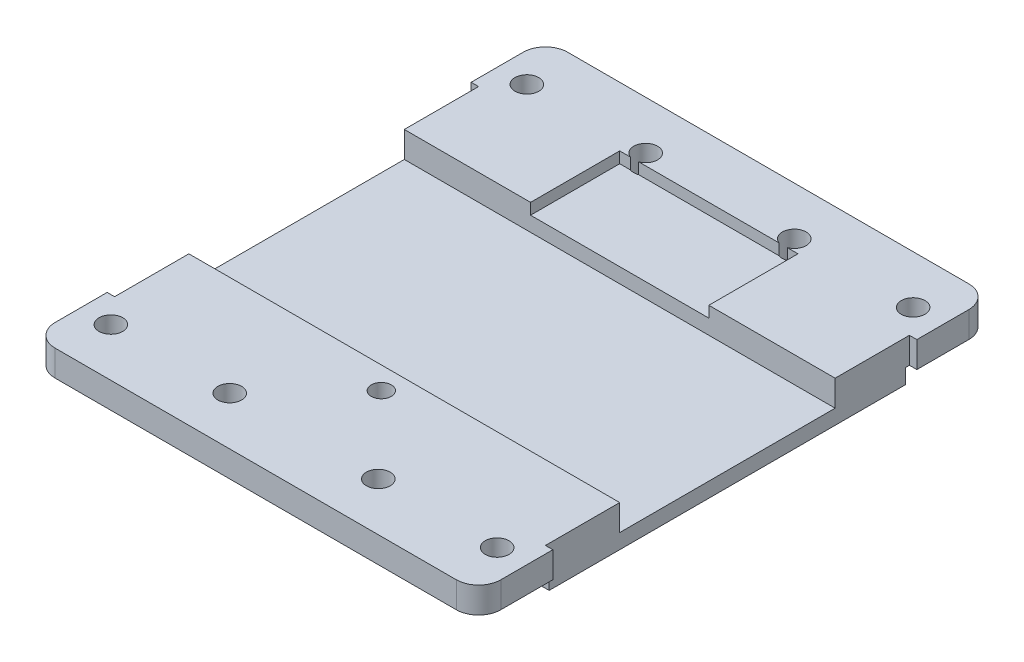
from build123d import *

# Parameters (mm, degrees)
SKETCH1_W           = 60
SKETCH1_H           = 48
BOSS_EXTRUDE1_DEPTH = 2
BOSS_EXTRUDE2_DEPTH = 3.5
SKETCH3_W           = 6.52386431
SKETCH3_H           = 49
SKETCH3_W_2         = 6.523864309
CUT_EXTRUDE2_DEPTH  = 15
SKETCH4_W           = 24
SKETCH4_H           = 12
CUT_EXTRUDE3_DEPTH  = 1.5
SKETCH5_R           = 1.35
CUT_EXTRUDE4_DEPTH  = 3
SKETCH6_R           = 1.35
CUT_EXTRUDE5_DEPTH  = 3
SKETCH7_W           = 69.929961246
SKETCH7_H           = 12.314710156
SKETCH7_W_2         = 77.406749556
SKETCH7_H_2         = 16.199708004
CUT_EXTRUDE6_DEPTH  = 2
SKETCH8_R           = 1.6
CUT_EXTRUDE7_DEPTH  = 18
SKETCH9_W           = 6.597166155
SKETCH9_H           = 6.303958771
SKETCH9_W_2         = 5.93744954
SKETCH9_H_2         = 5.497638462
SKETCH9_W_3         = 7.769995694
SKETCH9_W_4         = 5.131129232
SKETCH9_H_3         = 5.204431078
SKETCH9_W_5         = 5.497638463
SKETCH9_H_4         = 5.0930957
SKETCH9_W_6         = 4.691318155
BOSS_EXTRUDE3_DEPTH = 3.5
SKETCH10_W          = 13.673673514
SKETCH10_H          = 2.686711401
SKETCH10_W_2        = 10.911645047
SKETCH10_H_2        = 3.141048784
SKETCH10_W_3        = 10.921694408
SKETCH10_H_3        = 3.054325349
SKETCH10_W_4        = 12
BOSS_EXTRUDE4_DEPTH = 3.5


with BuildPart() as part:
    # Sketch1 → Boss-Extrude1 (new body)
    with BuildSketch(Plane(origin=(0, 0, 0), x_dir=(1, 0, 0), z_dir=(0, 1, 0))):
        with Locations((0.094538135, 3.403372847)):
            Rectangle(SKETCH1_W, SKETCH1_H)
        with BuildLine():
            Line((-29.905461865, -20.596627153), (-29.905461865, -28.096627153))
            ThreePointArc((-29.905461865, -28.096627153), (-29.026782209, -30.217947496), (-26.905461865, -31.096627153))
            Line((-26.905461865, -31.096627153), (-24.905461865, -31.096627153))
            Line((-24.905461865, -31.096627153), (-24.905461865, -29.096627153))
            Line((-24.905461865, -29.096627153), (-14.905461865, -29.096627153))
            Line((-14.905461865, -29.096627153), (-14.905461865, -31.096627153))
            Line((-14.905461865, -31.096627153), (13.094538135, -31.096627153))
            Line((13.094538135, -31.096627153), (13.094538135, -29.096627153))
            Line((13.094538135, -29.096627153), (23.094538135, -29.096627153))
            Line((23.094538135, -29.096627153), (23.094538135, -31.096627153))
            Line((23.094538135, -31.096627153), (27.094538135, -31.096627153))
            ThreePointArc((27.094538135, -31.096627153), (29.215858478, -30.217947496), (30.094538135, -28.096627153))
            Line((30.094538135, -28.096627153), (30.094538135, -20.596627153))
            Line((30.094538135, -20.596627153), (-29.905461865, -20.596627153))
        make_face()
        with BuildLine():
            Line((30.094538135, 27.403372847), (30.094538135, 34.903372847))
            ThreePointArc((30.094538135, 34.903372847), (29.215858478, 37.024693191), (27.094538135, 37.903372847))
            Line((27.094538135, 37.903372847), (25.094538135, 37.903372847))
            Line((25.094538135, 37.903372847), (25.094538135, 35.903372847))
            Line((25.094538135, 35.903372847), (15.094538135, 35.903372847))
            Line((15.094538135, 35.903372847), (15.094538135, 37.903372847))
            Line((15.094538135, 37.903372847), (-12.905461865, 37.903372847))
            Line((-12.905461865, 37.903372847), (-12.905461865, 35.903372847))
            Line((-12.905461865, 35.903372847), (-22.905461865, 35.903372847))
            Line((-22.905461865, 35.903372847), (-22.905461865, 37.903372847))
            Line((-22.905461865, 37.903372847), (-26.905461865, 37.903372847))
            ThreePointArc((-26.905461865, 37.903372847), (-29.026782209, 37.024693191), (-29.905461865, 34.903372847))
            Line((-29.905461865, 34.903372847), (-29.905461865, 27.403372847))
            Line((-29.905461865, 27.403372847), (30.094538135, 27.403372847))
        make_face()
    extrude(amount=BOSS_EXTRUDE1_DEPTH)

    # Sketch2 → Boss-Extrude2 (add)
    with BuildSketch(Plane(origin=(0, 2, 0), x_dir=(1, 0, 0), z_dir=(0, 1, 0))):
        with BuildLine():
            Line((30.094538135, -11.096627153), (-29.905461865, -11.096627153))
            Line((-29.905461865, -11.096627153), (-29.905461865, -28.096627153))
            ThreePointArc((-29.905461865, -28.096627153), (-29.026782209, -30.217947496), (-26.905461865, -31.096627153))
            Line((-26.905461865, -31.096627153), (-24.905461865, -31.096627153))
            Line((-24.905461865, -31.096627153), (-24.905461865, -29.096627153))
            Line((-24.905461865, -29.096627153), (-14.905461865, -29.096627153))
            Line((-14.905461865, -29.096627153), (-14.905461865, -31.096627153))
            Line((-14.905461865, -31.096627153), (13.094538135, -31.096627153))
            Line((13.094538135, -31.096627153), (13.094538135, -29.096627153))
            Line((13.094538135, -29.096627153), (23.094538135, -29.096627153))
            Line((23.094538135, -29.096627153), (23.094538135, -31.096627153))
            Line((23.094538135, -31.096627153), (27.094538135, -31.096627153))
            ThreePointArc((27.094538135, -31.096627153), (29.215858478, -30.217947496), (30.094538135, -28.096627153))
            Line((30.094538135, -28.096627153), (30.094538135, -11.096627153))
        make_face()
        with BuildLine():
            Line((-29.905461865, 34.903372847), (-29.905461865, 17.903372847))
            Line((-29.905461865, 17.903372847), (30.094538135, 17.903372847))
            Line((30.094538135, 17.903372847), (30.094538135, 34.903372847))
            ThreePointArc((30.094538135, 34.903372847), (29.215858478, 37.024693191), (27.094538135, 37.903372847))
            Line((27.094538135, 37.903372847), (25.094538135, 37.903372847))
            Line((25.094538135, 37.903372847), (25.094538135, 35.903372847))
            Line((25.094538135, 35.903372847), (15.094538135, 35.903372847))
            Line((15.094538135, 35.903372847), (15.094538135, 37.903372847))
            Line((15.094538135, 37.903372847), (-12.905461865, 37.903372847))
            Line((-12.905461865, 37.903372847), (-12.905461865, 35.903372847))
            Line((-12.905461865, 35.903372847), (-22.905461865, 35.903372847))
            Line((-22.905461865, 35.903372847), (-22.905461865, 37.903372847))
            Line((-22.905461865, 37.903372847), (-26.905461865, 37.903372847))
            ThreePointArc((-26.905461865, 37.903372847), (-29.026782209, 37.024693191), (-29.905461865, 34.903372847))
        make_face()
    extrude(amount=BOSS_EXTRUDE2_DEPTH)

    # Sketch3 → Cut-Extrude2 (cut)
    with BuildSketch(Plane(origin=(0, 5.5, 0), x_dir=(1, 0, 0), z_dir=(0, 1, 0))):
        with Locations((-32.16739402, 3.403372847)):
            Rectangle(SKETCH3_W, SKETCH3_H)
        with Locations((32.35647029, 3.403372847)):
            Rectangle(SKETCH3_W_2, SKETCH3_H)
    extrude(amount=-CUT_EXTRUDE2_DEPTH, mode=Mode.SUBTRACT)

    # Sketch4 → Cut-Extrude3 (cut)
    with BuildSketch(Plane(origin=(0, 5.5, 0), x_dir=(1, 0, 0), z_dir=(0, 1, 0))):
        with Locations((0.094538135, 23.903372847)):
            Rectangle(SKETCH4_W, SKETCH4_H)
    extrude(amount=-CUT_EXTRUDE3_DEPTH, mode=Mode.SUBTRACT)

    # Sketch5 → Cut-Extrude4 (cut)
    with BuildSketch(Plane(origin=(0, 5.5, 0), x_dir=(1, 0, 0), z_dir=(0, 1, 0))):
        with Locations((0, -14.096627153)):
            Circle(SKETCH5_R)
    extrude(amount=-CUT_EXTRUDE4_DEPTH, mode=Mode.SUBTRACT)

    # Sketch6 → Cut-Extrude5 (cut)
    with BuildSketch(Plane(origin=(0, 5.5, 0), x_dir=(1, 0, 0), z_dir=(0, 1, 0))):
        with Locations((20.770286942, 25.903372847)):
            Circle(SKETCH6_R)
        with Locations((0, 31.903372847)):
            Circle(SKETCH6_R)
        with Locations((-20.187989902, 25.903372847)):
            Circle(SKETCH6_R)
        with Locations((-20.187989902, -19.096627153)):
            Circle(SKETCH6_R)
        with Locations((0, -25.096627153)):
            Circle(SKETCH6_R)
        with Locations((20.770286942, -19.096627153)):
            Circle(SKETCH6_R)
    extrude(amount=-CUT_EXTRUDE5_DEPTH, mode=Mode.SUBTRACT)

    # Sketch7 → Cut-Extrude6 (cut)
    with BuildSketch(Plane.XZ):
        with Locations((1.157414904, 26.753982231)):
            Rectangle(SKETCH7_W, SKETCH7_H)
        with Locations((2.037037058, -35.503226849)):
            Rectangle(SKETCH7_W_2, SKETCH7_H_2)
    extrude(amount=-CUT_EXTRUDE6_DEPTH, mode=Mode.SUBTRACT)

    # Sketch8 → Cut-Extrude7 (cut)
    with BuildSketch(Plane.XZ.offset(-2)):
        with Locations((-25.905461865, -31.403372847)):
            Circle(SKETCH8_R)
        with Locations((-9.905461865, -31.403372847)):
            Circle(SKETCH8_R)
        with Locations((10.094538135, -31.403372847)):
            Circle(SKETCH8_R)
        with Locations((26.094538135, -31.403372847)):
            Circle(SKETCH8_R)
        with Locations((26.094538135, 24.596627153)):
            Circle(SKETCH8_R)
        with Locations((10.094538135, 24.596627153)):
            Circle(SKETCH8_R)
        with Locations((-9.905461865, 24.596627153)):
            Circle(SKETCH8_R)
        with Locations((-25.905461865, 24.596627153)):
            Circle(SKETCH8_R)
    extrude(amount=-CUT_EXTRUDE7_DEPTH, mode=Mode.SUBTRACT)

    # Sketch9 → Boss-Extrude3 (add)
    with BuildSketch(Plane(origin=(0, 5.5, 0), x_dir=(1, 0, 0), z_dir=(0, 1, 0))):
        with Locations((-0.455225712, -25.037743467)):
            Rectangle(SKETCH9_W, SKETCH9_H)
        with Locations((20.399149524, -19.13694485)):
            Rectangle(SKETCH9_W_2, SKETCH9_H_2)
        with Locations((-21.272950024, -19.13694485)):
            Rectangle(SKETCH9_W_3, SKETCH9_H_2)
        with Locations((-20.759837101, 26.236897929)):
            Rectangle(SKETCH9_W_4, SKETCH9_H_3)
        with Locations((0.094538135, 32.449920697)):
            Rectangle(SKETCH9_W_5, SKETCH9_H_4)
        with Locations((20.362498601, 26.236897929)):
            Rectangle(SKETCH9_W_6, SKETCH9_H_3)
    extrude(amount=-BOSS_EXTRUDE3_DEPTH)

    # Sketch10 → Boss-Extrude4 (add)
    with BuildSketch(Plane.XZ.offset(-2)):
        with Locations((-18.068625108, 29.753271453)):
            Rectangle(SKETCH10_W, SKETCH10_H)
        with Locations((18.550360659, 29.526102761)):
            Rectangle(SKETCH10_W_2, SKETCH10_H_2)
        with Locations((-18.366309069, -36.376210173)):
            Rectangle(SKETCH10_W_3, SKETCH10_H_3)
        with Locations((19.094538135, -36.376210173)):
            Rectangle(SKETCH10_W_4, SKETCH10_H_3)
    extrude(amount=-BOSS_EXTRUDE4_DEPTH)


solid = part.part
